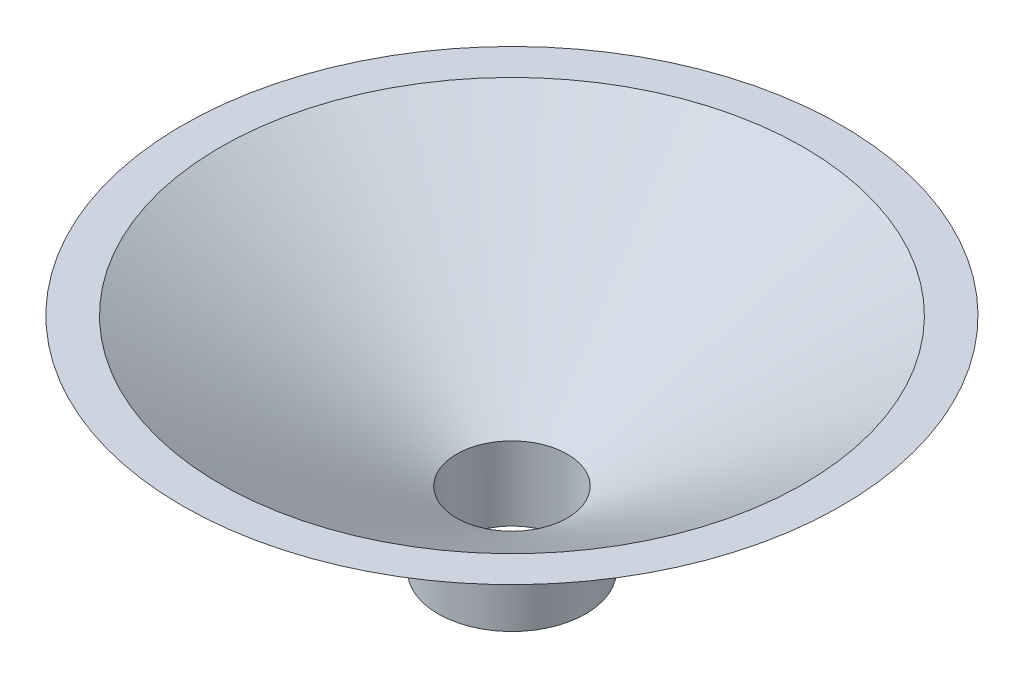
from build123d import *

# Parameters (mm, degrees)
SKETCH1_R           = 10
SKETCH1_R_2         = 7.5
BOSS_EXTRUDE1_DEPTH = 10
SKETCH6_R           = 10
BOSS_EXTRUDE3_DEPTH = 20
BOSS_EXTRUDE3_TAPER = -60
SKETCH8_R           = 7.5
CUT_EXTRUDE3_DEPTH  = 20
CUT_EXTRUDE3_TAPER  = -58


with BuildPart() as part:
    # Sketch1 → Boss-Extrude1 (new body)
    with BuildSketch(Plane(origin=(0, 0, 0), x_dir=(1, 0, 0), z_dir=(0, 1, 0))):
        Circle(SKETCH1_R)
        Circle(SKETCH1_R_2, mode=Mode.SUBTRACT)
    extrude(amount=BOSS_EXTRUDE1_DEPTH)

    # Sketch6 → Boss-Extrude3 (add)
    with BuildSketch(Plane(origin=(0, 10, 0), x_dir=(1, 0, 0), z_dir=(0, 1, 0))):
        Circle(SKETCH6_R)
    extrude(amount=BOSS_EXTRUDE3_DEPTH, taper=BOSS_EXTRUDE3_TAPER)

    # Sketch8 → Cut-Extrude3 (cut)
    with BuildSketch(Plane.XZ.offset(-10)):
        Circle(SKETCH8_R)
    extrude(amount=-CUT_EXTRUDE3_DEPTH, taper=CUT_EXTRUDE3_TAPER, mode=Mode.SUBTRACT)


solid = part.part
